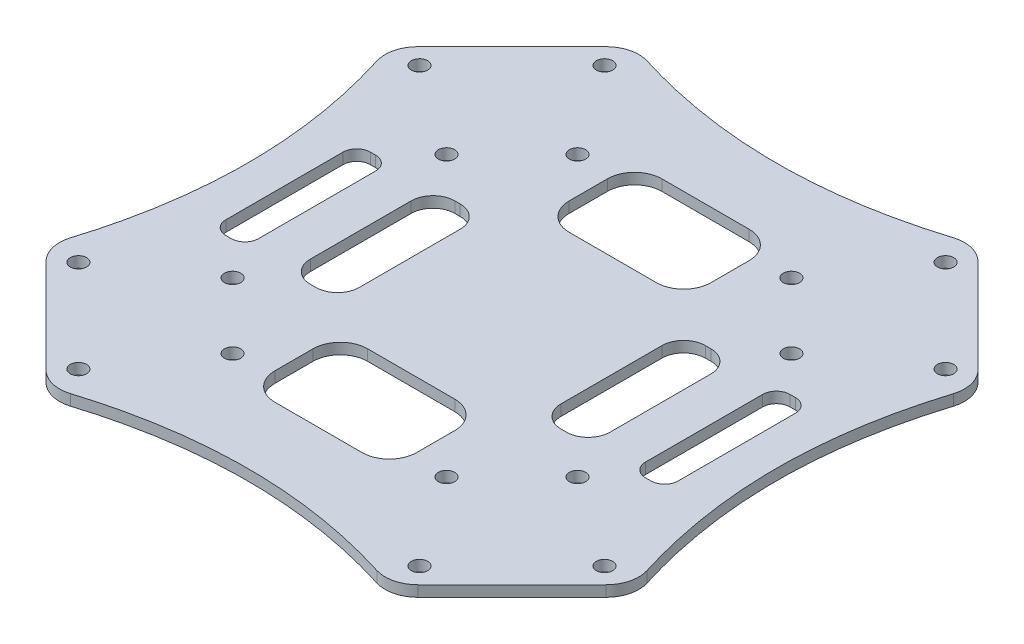
from build123d import *

# Parameters (mm, degrees)
EXTRUDE_1_DEPTH     = 2
FILLET_1_R          = 6
SKETCH_3_R          = 1.5
SKETCH_3_R_2        = 1.500000001
CUT_EXTRUDE_1_DEPTH = 10


with BuildPart() as part:
    # Эскиз2 → Бобышка-Вытянуть1 (new body)
    with BuildSketch(Plane(origin=(0, 0, 0), x_dir=(1, 0, 0), z_dir=(0, 1, 0))):
        with BuildLine():
            Line((31.5, -54), (54, -31.5))
            add(Edge.make_bspline(
                [(54, 31.5), (43, 0), (54, -31.5)],
                knots=[0, 0, 0, 1, 1, 1], degree=2))
            Line((54, 31.5), (31.5, 54))
            add(Edge.make_bspline(
                [(31.5, 54), (0, 43), (-31.5, 54)],
                knots=[0, 0, 0, 1, 1, 1], degree=2))
            Line((-31.5, 54), (-54, 31.5))
            add(Edge.make_bspline(
                [(-54, 31.5), (-48.5, 15.75), (-48.5, 0)],
                knots=[0, 0, 0, 0.5, 0.5, 0.5], degree=2))
            add(Edge.make_bspline(
                [(-48.5, 0), (-48.5, -15.75), (-54, -31.5)],
                knots=[0.5, 0.5, 0.5, 1, 1, 1], degree=2))
            Line((-54, -31.5), (-31.5, -54))
            add(Edge.make_bspline(
                [(31.5, -54), (0, -43), (-31.5, -54)],
                knots=[0, 0, 0, 1, 1, 1], degree=2))
        make_face()
        with BuildLine():
            Line((8, -35.5), (0, -35.5))
            Line((0, -35.5), (-8, -35.5))
            ThreePointArc((-8, -35.5), (-11.535533906, -34.035533906), (-13, -30.5))
            Line((-13, -30.5), (-13, -23.5))
            ThreePointArc((-13, -23.5), (-11.535533906, -19.964466094), (-8, -18.5))
            Line((-8, -18.5), (8, -18.5))
            ThreePointArc((8, -18.5), (11.535533906, -19.964466094), (13, -23.5))
            Line((13, -23.5), (13, -30.5))
            ThreePointArc((13, -30.5), (11.535533906, -34.035533906), (8, -35.5))
        make_face(mode=Mode.SUBTRACT)
        with BuildLine():
            Line((-41.5, -11.006602376), (-41.5, 0))
            Line((-41.5, 0), (-41.5, 10.5))
            ThreePointArc((-41.5, 10.5), (-40.767766953, 12.267766953), (-39, 13))
            Line((-39, 13), (-38, 13))
            ThreePointArc((-38, 13), (-36.232233047, 12.267766953), (-35.5, 10.5))
            Line((-35.5, 10.5), (-35.5, 0))
            Line((-35.5, 0), (-35.5, -11.006602376))
            ThreePointArc((-35.5, -11.006602376), (-36.232233047, -12.774369329), (-38, -13.506602376))
            Line((-38, -13.506602376), (-39, -13.506602376))
            ThreePointArc((-39, -13.506602376), (-40.767766953, -12.774369329), (-41.5, -11.006602376))
        make_face(mode=Mode.SUBTRACT)
        with BuildLine():
            Line((-27.5, -9.506602376), (-27.5, 0))
            Line((-27.5, 0), (-27.5, 9))
            ThreePointArc((-27.5, 9), (-26.328427125, 11.828427125), (-23.5, 13))
            Line((-23.5, 13), (-22.5, 13))
            ThreePointArc((-22.5, 13), (-19.671572875, 11.828427125), (-18.5, 9))
            Line((-18.5, 9), (-18.5, -9.506602376))
            ThreePointArc((-18.5, -9.506602376), (-19.671572875, -12.335029501), (-22.5, -13.506602376))
            Line((-22.5, -13.506602376), (-23.5, -13.506602376))
            ThreePointArc((-23.5, -13.506602376), (-26.328427125, -12.335029501), (-27.5, -9.506602376))
        make_face(mode=Mode.SUBTRACT)
        with BuildLine():
            Line((27.5, 0), (27.5, -9.506602376))
            ThreePointArc((27.5, -9.506602376), (26.328427125, -12.335029501), (23.5, -13.506602376))
            Line((23.5, -13.506602376), (22.5, -13.506602376))
            ThreePointArc((22.5, -13.506602376), (19.671572875, -12.335029501), (18.5, -9.506602376))
            Line((18.5, -9.506602376), (18.5, 9))
            ThreePointArc((18.5, 9), (19.671572875, 11.828427125), (22.5, 13))
            Line((22.5, 13), (23.5, 13))
            ThreePointArc((23.5, 13), (26.328427125, 11.828427125), (27.5, 9))
            Line((27.5, 9), (27.5, 0))
        make_face(mode=Mode.SUBTRACT)
        with BuildLine():
            Line((35.5, -11.006602376), (35.5, 0))
            Line((35.5, 0), (35.5, 10.5))
            ThreePointArc((35.5, 10.5), (36.232233047, 12.267766953), (38, 13))
            Line((38, 13), (39, 13))
            ThreePointArc((39, 13), (40.767766953, 12.267766953), (41.5, 10.5))
            Line((41.5, 10.5), (41.5, 0))
            Line((41.5, 0), (41.5, -11.006602376))
            ThreePointArc((41.5, -11.006602376), (40.767766953, -12.774369329), (39, -13.506602376))
            Line((39, -13.506602376), (38, -13.506602376))
            ThreePointArc((38, -13.506602376), (36.232233047, -12.774369329), (35.5, -11.006602376))
        make_face(mode=Mode.SUBTRACT)
        with BuildLine():
            Line((13, 30.5), (13, 23.5))
            ThreePointArc((13, 23.5), (11.535533906, 19.964466094), (8, 18.5))
            Line((8, 18.5), (-8, 18.5))
            ThreePointArc((-8, 18.5), (-11.535533906, 19.964466094), (-13, 23.5))
            Line((-13, 23.5), (-13, 30.5))
            ThreePointArc((-13, 30.5), (-11.535533906, 34.035533906), (-8, 35.5))
            Line((-8, 35.5), (0, 35.5))
            Line((0, 35.5), (8, 35.5))
            ThreePointArc((8, 35.5), (11.535533906, 34.035533906), (13, 30.5))
        make_face(mode=Mode.SUBTRACT)
    extrude(amount=EXTRUDE_1_DEPTH)

    # Скругление1
    fillet_1_edges = [part.edges().sort_by_distance(p)[0] for p in [
        (-31.5, 1, 54),
        (-54, 1, 31.5),
        (-54, 1, -31.5),
        (-31.5, 1, -54),
        (31.5, 1, -54),
        (54, 1, -31.5),
        (54, 1, 31.5),
        (31.5, 1, 54),
    ]]
    fillet(fillet_1_edges, radius=FILLET_1_R)

    # Эскиз3 → Вырез-Вытянуть1 (cut)
    with BuildSketch(Plane.XZ):
        with Locations((-19.622213178, 31.643028458)):
            Circle(SKETCH_3_R)
        with Locations((-31.643028458, 19.622213178)):
            Circle(SKETCH_3_R_2)
        with Locations((-48.260037816, 31.289475068)):
            Circle(SKETCH_3_R)
        with Locations((-31.289475068, 48.260037816)):
            Circle(SKETCH_3_R)
        with Locations((19.622213178, 31.643028458)):
            Circle(SKETCH_3_R)
        with Locations((31.643028458, 19.622213178)):
            Circle(SKETCH_3_R)
        with Locations((48.260037816, 31.289475068)):
            Circle(SKETCH_3_R)
        with Locations((31.289475068, 48.260037816)):
            Circle(SKETCH_3_R)
        with Locations((31.643028458, -19.622213178)):
            Circle(SKETCH_3_R)
        with Locations((48.260037816, -31.289475068)):
            Circle(SKETCH_3_R)
        with Locations((31.289475068, -48.260037816)):
            Circle(SKETCH_3_R)
        with Locations((19.622213178, -31.643028458)):
            Circle(SKETCH_3_R)
        with Locations((-19.622213178, -31.643028458)):
            Circle(SKETCH_3_R)
        with Locations((-31.643028458, -19.622213178)):
            Circle(SKETCH_3_R)
        with Locations((-48.260037816, -31.289475068)):
            Circle(SKETCH_3_R)
        with Locations((-31.289475068, -48.260037816)):
            Circle(SKETCH_3_R)
    extrude(amount=-CUT_EXTRUDE_1_DEPTH, mode=Mode.SUBTRACT)


solid = part.part
